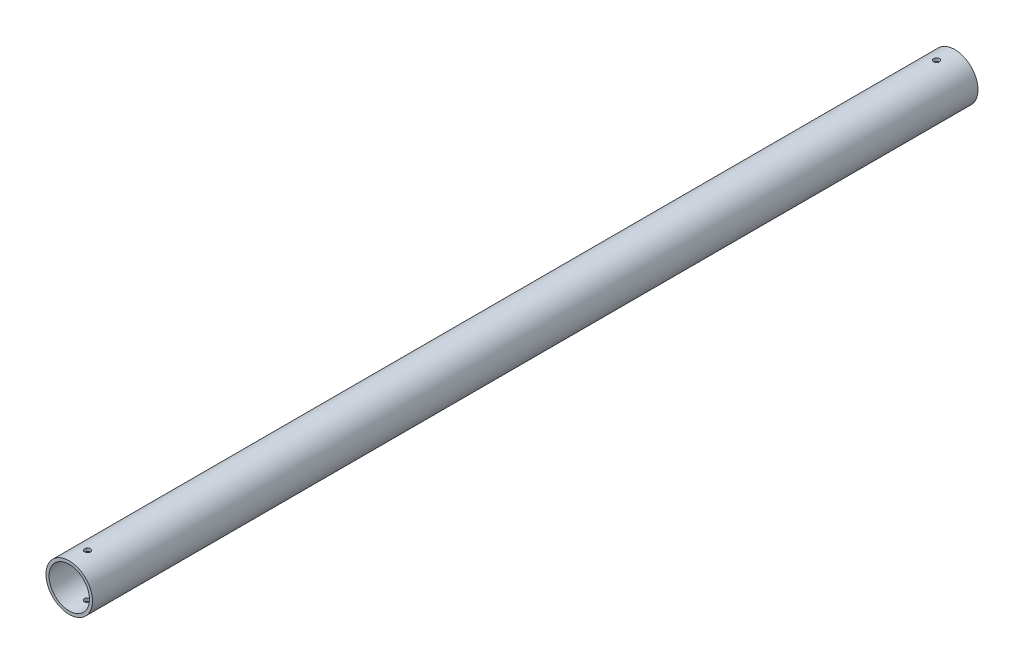
from build123d import *

# Parameters (mm, degrees)
SKETCH1_R           = 12.7
SKETCH1_R_2         = 11.049
BOSS_EXTRUDE1_DEPTH = 242
SKETCH2_R           = 1.6
CUT_EXTRUDE1_DEPTH  = 13.7


with BuildPart() as part:
    # Sketch1 → Boss-Extrude1 (new body, symmetric)
    with BuildSketch(Plane.XY):
        Circle(SKETCH1_R)
        Circle(SKETCH1_R_2, mode=Mode.SUBTRACT)
    extrude(amount=BOSS_EXTRUDE1_DEPTH, both=True)

    # Sketch2 → Cut-Extrude1 (cut, symmetric)
    with BuildSketch(Plane(origin=(0, 0, 0), x_dir=(1, 0, 0), z_dir=(0, 1, 0))):
        with Locations((0, -232)):
            Circle(SKETCH2_R)
    cut_extrude1 = extrude(amount=CUT_EXTRUDE1_DEPTH, both=True, mode=Mode.SUBTRACT)

    # Mirror1: Cut-Extrude1 across plane
    add(cut_extrude1.mirror(Plane.XY), mode=Mode.SUBTRACT)


solid = part.part
